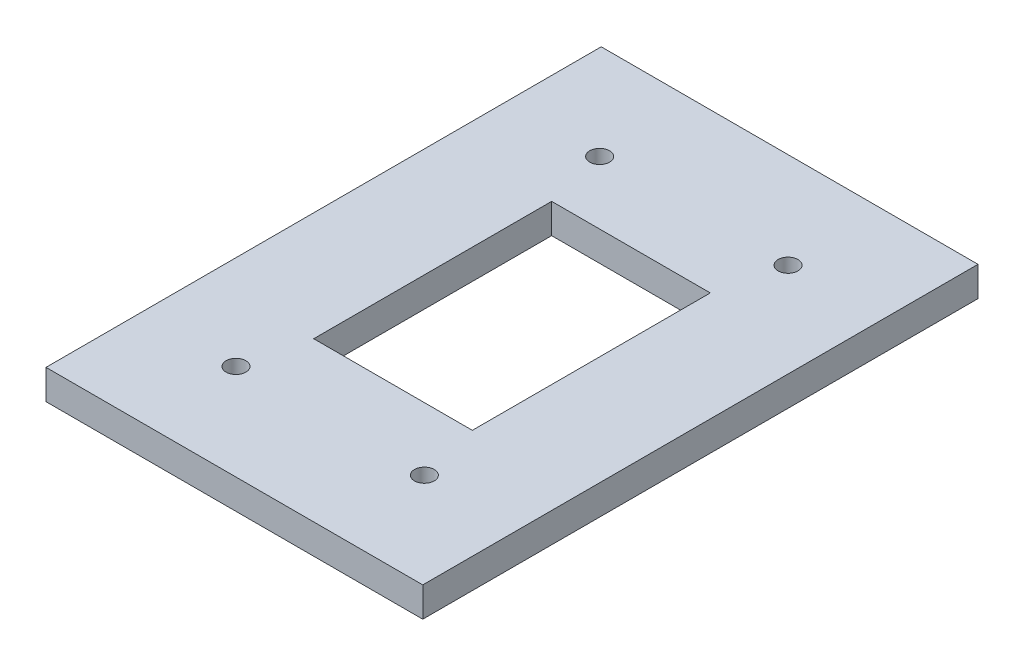
from build123d import *

# Parameters (mm, degrees)
SKETCH1_W               = 241.3
SKETCH1_H               = 355.6
BOSS_EXTRUDE1_DEPTH     = 9.525
SKETCH2_R               = 6.35
CUT_EXTRUDE1_DEPTH      = 20.05
SKETCH3_W               = 101.6
SKETCH3_H               = 152.4
CUT_EXTRUDE2_DEPTH      = 1
CUT_EXTRUDE2_DEPTH_BACK = 20.05


with BuildPart() as part:
    # Sketch1 → Boss-Extrude1 (new body, symmetric)
    with BuildSketch(Plane(origin=(0, 0, 0), x_dir=(1, 0, 0), z_dir=(0, 1, 0))):
        Rectangle(SKETCH1_W, SKETCH1_H)
    extrude(amount=BOSS_EXTRUDE1_DEPTH, both=True)

    # Sketch2 → Cut-Extrude1 (cut, through all)
    with BuildSketch(Plane(origin=(0, 9.525, 0), x_dir=(1, 0, 0), z_dir=(0, 1, 0))):
        with Locations((-60.325, 116.459)):
            Circle(SKETCH2_R)
        with Locations((60.325, 116.459)):
            Circle(SKETCH2_R)
        with Locations((60.325, -116.459)):
            Circle(SKETCH2_R)
        with Locations((-60.325, -116.459)):
            Circle(SKETCH2_R)
    extrude(amount=-CUT_EXTRUDE1_DEPTH, mode=Mode.SUBTRACT)

    # Sketch3 → Cut-Extrude2 (cut, two sides)
    with BuildSketch(Plane(origin=(0, 9.525, 0), x_dir=(1, 0, 0), z_dir=(0, 1, 0))) as cut_extrude2_sk:
        Rectangle(SKETCH3_W, SKETCH3_H)
    extrude(amount=CUT_EXTRUDE2_DEPTH, mode=Mode.SUBTRACT)
    extrude(cut_extrude2_sk.sketch, amount=-CUT_EXTRUDE2_DEPTH_BACK, mode=Mode.SUBTRACT)


solid = part.part
